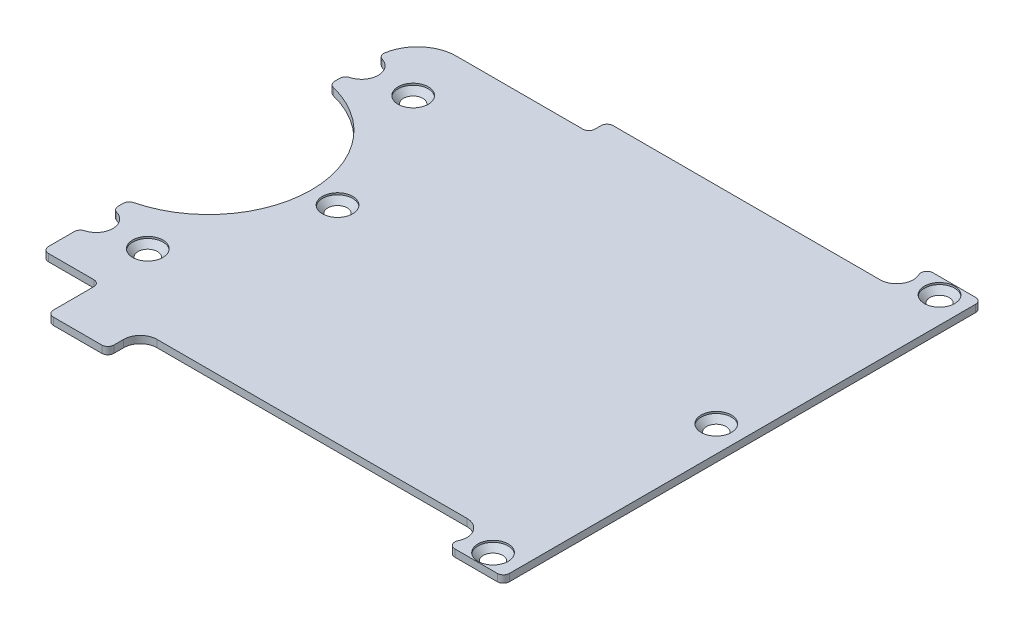
from build123d import *

# Parameters (mm, degrees)
SKETCH1_R                    = 1
BASE_SHAPE_DEPTH             = 0.6
FILLETS_R                    = 1
M2_5_COUNTERSUNKS_AT_2_COUNT = 2
M2_5_COUNTERSUNKS_AT_2_PITCH = 73.76
M2_5_COUNTERSUNKS_AT_3_COUNT = 2
M2_5_COUNTERSUNKS_AT_3_PITCH = 73.537756289
M2_5_COUNTERSUNKS_AT_4_COUNT = 2
M2_5_COUNTERSUNKS_AT_4_PITCH = 92.959345953
M2_5_COUNTERSUNKS_AT_5_COUNT = 2
M2_5_COUNTERSUNKS_AT_5_PITCH = 36.88
M2_5_COUNTERSUNKS_AT_6_COUNT = 2
M2_5_COUNTERSUNKS_AT_6_PITCH = 72.631898864


with BuildPart() as part:
    # Sketch1 → Base shape (new body, symmetric)
    with BuildSketch(Plane(origin=(0, 0, 0), x_dir=(1, 0, 0), z_dir=(0, 1, 0))):
        with BuildLine():
            ThreePointArc((2.75, 36.88), (1.944543648, 34.935456352), (0, 34.13))
            Line((0, 34.13), (-44.1, 34.13))
            ThreePointArc((-44.1, 34.13), (-44.807106781, 33.837106781), (-45.1, 33.13))
            Line((-45.1, 33.13), (-45.1, 32.13))
            ThreePointArc((-45.1, 32.13), (-45.392893219, 31.422893219), (-46.1, 31.13))
            Line((-46.1, 31.13), (-66.992025159, 31.13))
            ThreePointArc((-66.992025159, 31.13), (-71.559934966, 29.237909806), (-73.452025159, 24.67))
            ThreePointArc((-73.452025159, 24.67), (-71.507481511, 23.864543648), (-70.702025159, 21.92))
            ThreePointArc((-70.702025159, 21.92), (-71.507481511, 19.975456352), (-73.452025159, 19.17))
            Line((-73.452025159, 19.17), (-73.452025159, 16.662625843))
            ThreePointArc((-73.452025159, 16.662625843), (-63.663567803, 10.763596053), (-59.822025159, 0))
            ThreePointArc((-59.822025159, 0), (-63.663567803, -10.763596053), (-73.452025159, -16.662625843))
            Line((-73.452025159, -16.662625843), (-73.452025159, -19.17))
            ThreePointArc((-73.452025159, -19.17), (-71.507481511, -19.975456352), (-70.702025159, -21.92))
            ThreePointArc((-70.702025159, -21.92), (-71.507481511, -23.864543648), (-73.452025159, -24.67))
            Line((-73.452025159, -24.67), (-73.452025159, -30.8))
            Line((-73.452025159, -30.8), (-63.952025159, -30.8))
            Line((-63.952025159, -30.8), (-63.952025159, -34.13))
            Line((-63.952025159, -34.13), (-63.952025159, -39.5))
            Line((-63.952025159, -39.5), (-53.952025159, -39.5))
            Line((-53.952025159, -39.5), (-53.952025159, -36.88))
            ThreePointArc((-53.952025159, -36.88), (-53.146568808, -34.935456352), (-51.202025159, -34.13))
            Line((-51.202025159, -34.13), (0, -34.13))
            ThreePointArc((0, -34.13), (1.944543648, -34.935456352), (2.75, -36.88))
            ThreePointArc((2.75, -36.88), (2.220381771, -38.502468734), (0.835523788, -39.5))
            Line((0.835523788, -39.5), (11.4, -39.5))
            Line((11.4, -39.5), (11.4, 39.5))
            Line((11.4, 39.5), (0.835523788, 39.5))
            ThreePointArc((0.835523788, 39.5), (2.220381771, 38.502468734), (2.75, 36.88))
        make_face()
        with Locations((-64.925, -21.92)):
            Circle(SKETCH1_R, mode=Mode.SUBTRACT)
        with Locations((7.075, -36.88)):
            Circle(SKETCH1_R, mode=Mode.SUBTRACT)
        with Locations((-55.497025159, 0)):
            Circle(SKETCH1_R, mode=Mode.SUBTRACT)
        with Locations((-64.925, 21.92)):
            Circle(SKETCH1_R, mode=Mode.SUBTRACT)
        with Locations((7.075, 0)):
            Circle(SKETCH1_R, mode=Mode.SUBTRACT)
        with Locations((7.075, 36.88)):
            Circle(SKETCH1_R, mode=Mode.SUBTRACT)
    extrude(amount=BASE_SHAPE_DEPTH, both=True)

    # Fillets
    fillets_edges = [part.edges().sort_by_distance(p)[0] for p in [
        (0.835523788, -0.3, -39.5),
        (11.4, -0.3, -39.5),
        (11.4, -0.3, 39.5),
        (0.835523788, -0.3, 39.5),
        (-53.952025159, -0.3, 39.5),
        (-63.952025159, -0.3, 39.5),
        (-63.952025159, -0.3, 30.8),
        (-73.452025159, -0.3, 30.8),
        (-73.452025159, -0.3, 24.67),
        (-73.452025159, -0.3, 19.17),
        (-73.452025159, -0.3, 16.662625843),
        (-73.452025159, -0.3, -16.662625843),
        (-73.452025159, -0.3, -19.17),
        (-73.452025159, -0.3, -24.67),
    ]]
    fillet(fillets_edges, radius=FILLETS_R)

    # Sketch3 → M2.5 countersunks (revolve, cut)
    with BuildSketch(Plane(origin=(7.075, -0.6, -36.88), x_dir=(0, 0, -1), z_dir=(1, 0, 0))):
        Polygon((0, 0), (0, 1.2), (1.25, 1.2), (1.25, 1.55), (2.5, 0.3), (2.5, 0), align=None)
    m2_5_countersunks = revolve(axis=Axis((7.075, -6.95, -36.88), (0, 1, 0)), mode=Mode.SUBTRACT)

    # M2.5 countersunks at 2: M2.5 countersunks ×2
    with Locations(*[(0, 0, i * M2_5_COUNTERSUNKS_AT_2_PITCH) for i in range(1, M2_5_COUNTERSUNKS_AT_2_COUNT)]):
        add(m2_5_countersunks, mode=Mode.SUBTRACT)

    # M2.5 countersunks at 3: M2.5 countersunks ×2
    with Locations(*[Vector(-0.979088888, 0, 0.203432913) * (i * M2_5_COUNTERSUNKS_AT_3_PITCH) for i in range(1, M2_5_COUNTERSUNKS_AT_3_COUNT)]):
        add(m2_5_countersunks, mode=Mode.SUBTRACT)

    # M2.5 countersunks at 4: M2.5 countersunks ×2
    with Locations(*[Vector(-0.774532128, 0, 0.632534571) * (i * M2_5_COUNTERSUNKS_AT_4_PITCH) for i in range(1, M2_5_COUNTERSUNKS_AT_4_COUNT)]):
        add(m2_5_countersunks, mode=Mode.SUBTRACT)

    # M2.5 countersunks at 5: M2.5 countersunks ×2
    with Locations(*[(0, 0, i * M2_5_COUNTERSUNKS_AT_5_PITCH) for i in range(1, M2_5_COUNTERSUNKS_AT_5_COUNT)]):
        add(m2_5_countersunks, mode=Mode.SUBTRACT)

    # M2.5 countersunks at 6: M2.5 countersunks ×2
    with Locations(*[Vector(-0.861495103, 0, 0.507765879) * (i * M2_5_COUNTERSUNKS_AT_6_PITCH) for i in range(1, M2_5_COUNTERSUNKS_AT_6_COUNT)]):
        add(m2_5_countersunks, mode=Mode.SUBTRACT)


with BuildPart() as body_2:
    # Mirror1: mirrored copy
    add(part.part.mirror(Plane.ZX))


solid = body_2.part
